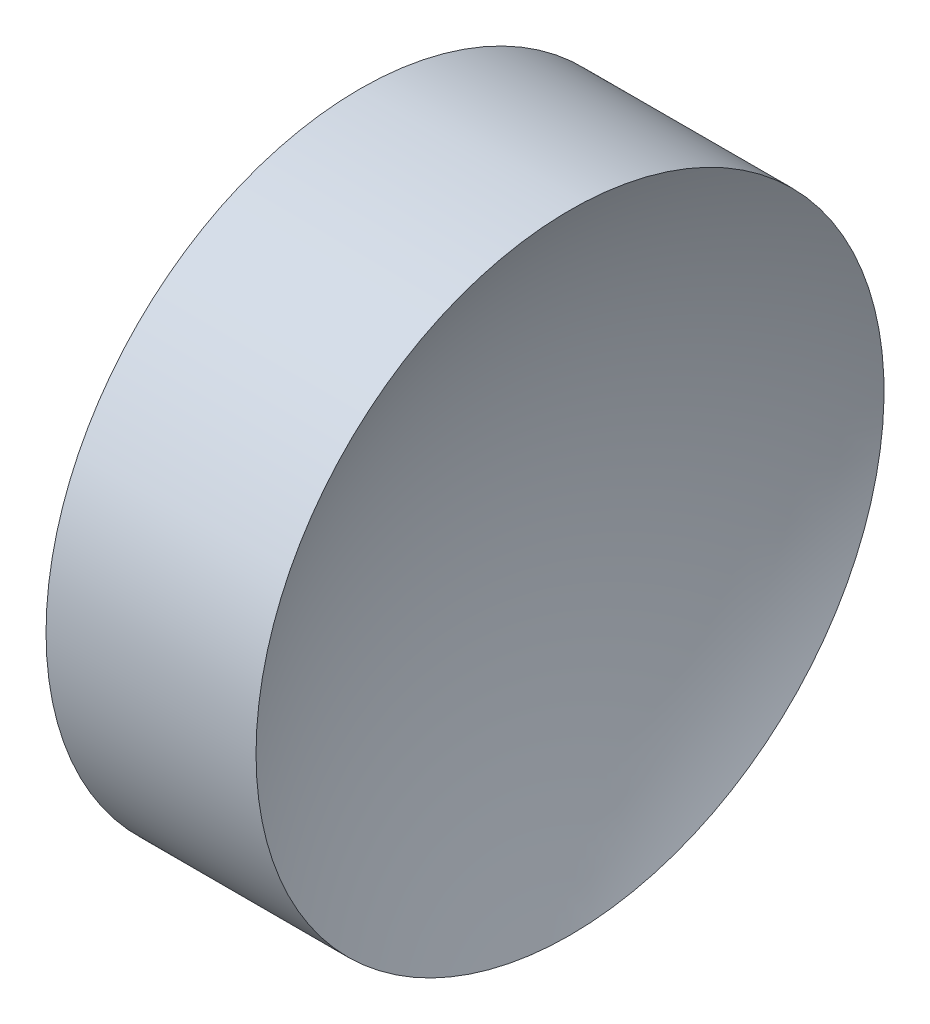
from build123d import *


with BuildPart() as part:
    # 草图1 → 旋转1 (revolve)
    with BuildSketch(Plane.XY, mode=Mode.PRIVATE) as revolve_1_sk:
        with BuildLine():
            Line((61.052485254, 32.611301436), (59.052485254, 32.611301436))
            ThreePointArc((59.052485254, 32.611301436), (58.245108902, 39.060338123), (55.872815974, 45.111301436))
            Line((55.872815974, 45.111301436), (60.052485254, 45.111301436))
            Line((60.052485254, 45.111301436), (64.232154534, 45.111301436))
            ThreePointArc((64.232154534, 45.111301436), (61.859861607, 39.060338123), (61.052485254, 32.611301436))
        make_face()
    revolve(revolve_1_sk.sketch.rotate(Axis((53.062326393, 32.611301436, 0), (1, 0, 0)), 90), axis=Axis((53.062326393, 32.611301436, 0), (1, 0, 0)))  # turned: the seam where the file's is


solid = part.part
